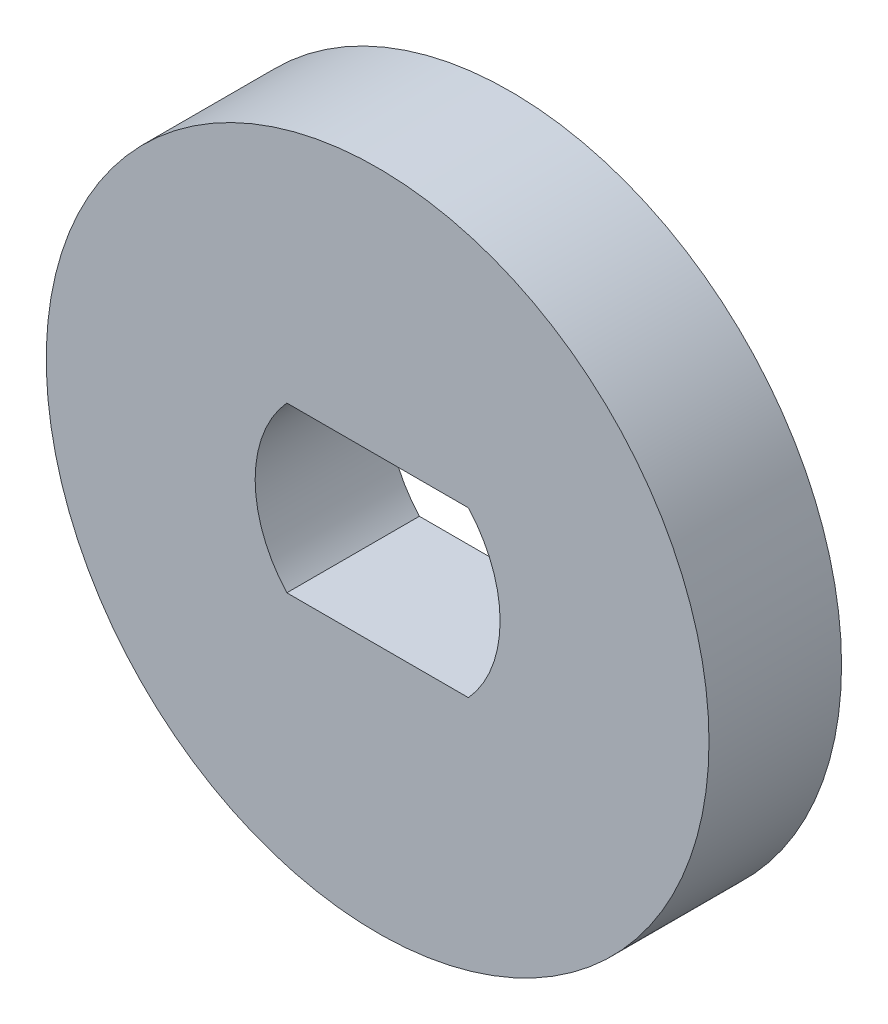
from build123d import *

# Parameters (mm, degrees)
SKETCH1_R           = 7.9375
BOSS_EXTRUDE1_DEPTH = 3.175


with BuildPart() as part:
    # Sketch1 → Boss-Extrude1 (new body)
    with BuildSketch(Plane.XY):
        Circle(SKETCH1_R)
        with BuildLine():
            ThreePointArc((-2.175224917, 1.9685), (-2.9337, 0), (-2.175224917, -1.9685))
            Line((-2.175224917, -1.9685), (2.175224917, -1.9685))
            ThreePointArc((2.175224917, -1.9685), (2.9337, 0), (2.175224917, 1.9685))
            Line((2.175224917, 1.9685), (-2.175224917, 1.9685))
        make_face(mode=Mode.SUBTRACT)
    extrude(amount=BOSS_EXTRUDE1_DEPTH)


solid = part.part
